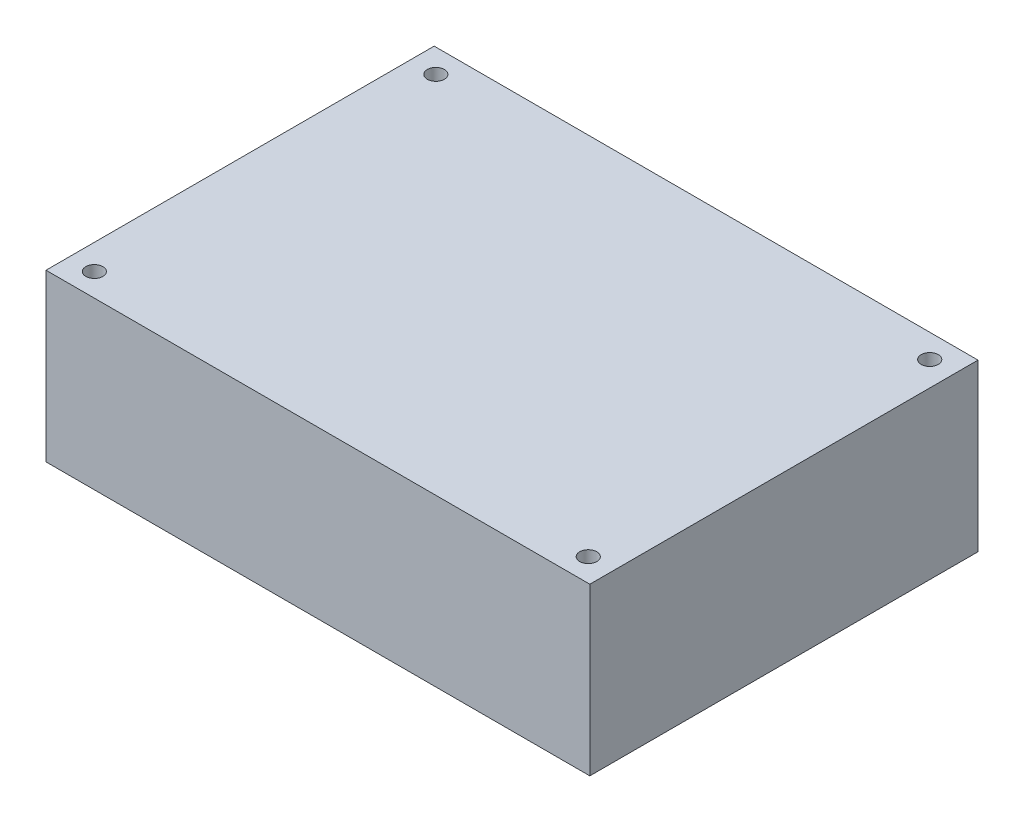
from build123d import *

# Parameters (mm, degrees)
SKETCH2_W            = 70.104
SKETCH2_H            = 50.038
BOSS_EXTRUDE1_DEPTH  = 21.3995
M2_CLEARANCE_HOLE1_D = 2.2


with BuildPart() as part:
    # Sketch2 → Boss-Extrude1 (new body)
    with BuildSketch(Plane(origin=(0, 0, 0), x_dir=(1, 0, 0), z_dir=(0, 1, 0))):
        Rectangle(SKETCH2_W, SKETCH2_H)
    extrude(amount=BOSS_EXTRUDE1_DEPTH)

    # M2 Clearance Hole1 (through all)
    with Locations(Plane(origin=(0, 0, 0), x_dir=(-1, 0, 0), z_dir=(0, -1, 0))):
        with Locations((-31.877, 21.971), (-31.877, -22.0472), (31.7881, -22.0472), (31.7881, 21.971)):
            Hole(M2_CLEARANCE_HOLE1_D / 2)


solid = part.part
